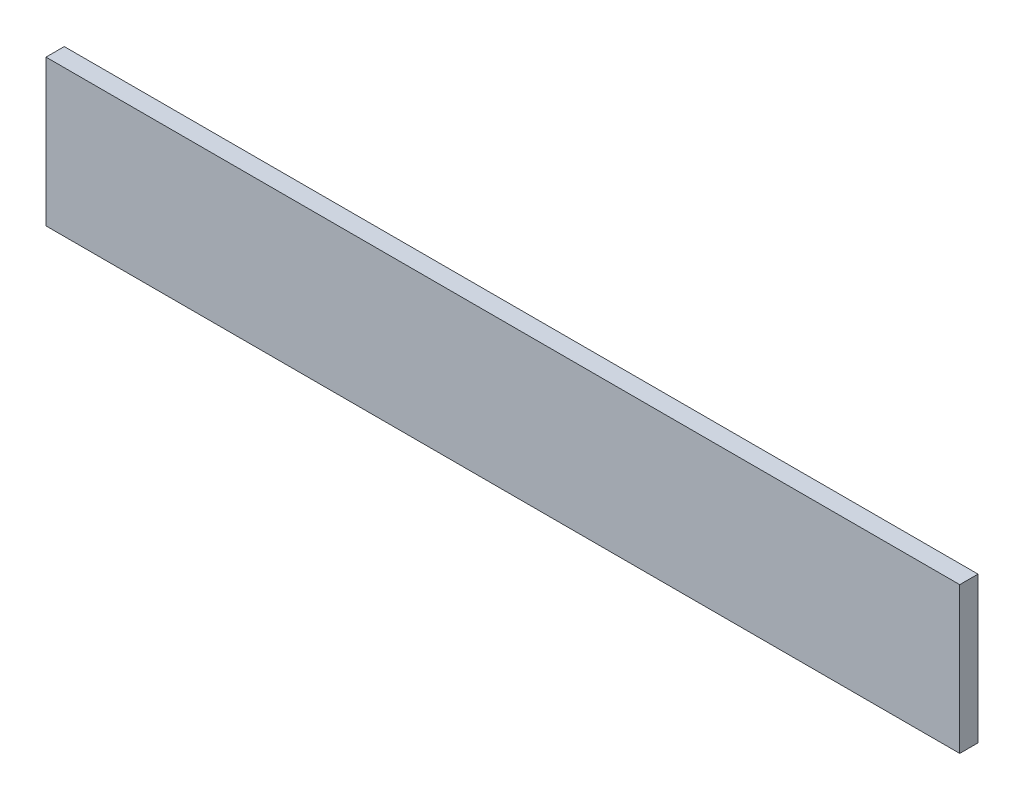
from build123d import *

# Parameters (mm, degrees)
ESQUISSE1_W        = 250
ESQUISSE1_H        = 40
BOSS_EXTRU_1_DEPTH = 5


with BuildPart() as part:
    # Esquisse1 → Boss.-Extru.1 (new body)
    with BuildSketch(Plane.XY):
        with Locations((-125, 20)):
            Rectangle(ESQUISSE1_W, ESQUISSE1_H)
    extrude(amount=BOSS_EXTRU_1_DEPTH)


solid = part.part
